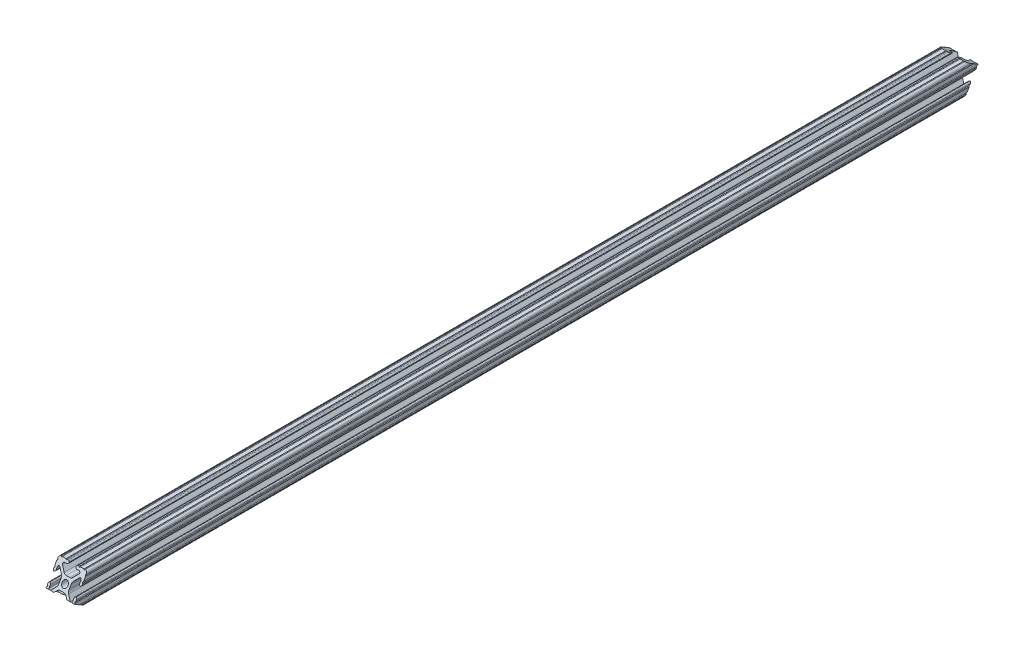
from build123d import *

# Parameters (mm, degrees)
SKETCH1_R                    = 2.6035
BOSS_EXTRUDE1_DEPTH          = 403.225
F_30_DEG_END_TRIM_DEPTH      = 13.7
F_30_DEG_END_TRIM_DEPTH_BACK = 13.7
TRIM_TO_FIT_DEPTH            = 13.7
TRIM_TO_FIT_DEPTH_BACK       = 13.7


with BuildPart() as part:
    # Sketch1 → Boss-Extrude1 (new body, symmetric)
    with BuildSketch(Plane.XY):
        with BuildLine():
            Line((-7.179650497, -8.645192506), (-3.952270251, -5.423690499))
            ThreePointArc((-3.952270251, -5.423690499), (-2.922936451, -4.736929036), (-1.709253557, -4.4958))
            Line((-1.709253557, -4.4958), (1.709253557, -4.4958))
            ThreePointArc((1.709253557, -4.4958), (2.922936451, -4.736929036), (3.952270251, -5.423690499))
            Line((3.952270251, -5.423690499), (7.179650497, -8.645192506))
            ThreePointArc((7.179650497, -8.645192506), (7.41473083, -9.822813117), (6.416408329, -10.4902))
            Line((6.416408329, -10.4902), (4.287512407, -10.4902))
            ThreePointArc((4.287512407, -10.4902), (3.54574862, -10.79744862), (3.2385, -11.539212407))
            Line((3.2385, -11.539212407), (3.2385, -11.650987593))
            ThreePointArc((3.2385, -11.650987593), (3.54574862, -12.39275138), (4.287512407, -12.7))
            Line((4.287512407, -12.7), (5.317126718, -12.7))
            ThreePointArc((5.317126718, -12.7), (5.825126718, -12.192), (6.333126718, -12.7))
            Line((6.333126718, -12.7), (9.550443118, -12.7))
            ThreePointArc((9.550443118, -12.7), (10.058366869, -12.192000006), (10.566443095, -12.699847501))
            ThreePointArc((10.566443095, -12.699847501), (12.082537762, -12.08250727), (12.699846982, -10.566399977))
            ThreePointArc((12.699846982, -10.566399977), (12.192000006, -10.058323491), (12.7, -9.5504))
            Line((12.7, -9.5504), (12.7, -6.3330836))
            ThreePointArc((12.7, -6.3330836), (12.192, -5.8250836), (12.7, -5.3170836))
            Line((12.7, -5.3170836), (12.7, -4.287469289))
            ThreePointArc((12.7, -4.287469289), (12.39275138, -3.545705502), (11.650987593, -3.238456882))
            Line((11.650987593, -3.238456882), (11.539212407, -3.238456882))
            ThreePointArc((11.539212407, -3.238456882), (10.79744862, -3.545705502), (10.4902, -4.287469289))
            Line((10.4902, -4.287469289), (10.4902, -6.402089023))
            ThreePointArc((10.4902, -6.402089023), (9.856505071, -7.351067942), (8.737131347, -7.129408934))
            Line((8.737131347, -7.129408934), (5.441005833, -3.840816462))
            ThreePointArc((5.441005833, -3.840816462), (4.750877967, -2.809883091), (4.5085, -1.593185507))
            Line((4.5085, -1.593185507), (4.5085, 1.593185507))
            ThreePointArc((4.5085, 1.593185507), (4.750877967, 2.809883091), (5.441005833, 3.840816462))
            Line((5.441005833, 3.840816462), (8.737131347, 7.129408934))
            ThreePointArc((8.737131347, 7.129408934), (9.856505071, 7.351067942), (10.4902, 6.402089023))
            Line((10.4902, 6.402089023), (10.4902, 4.287469289))
            ThreePointArc((10.4902, 4.287469289), (10.79744862, 3.545705502), (11.539212407, 3.238456882))
            Line((11.539212407, 3.238456882), (11.650987593, 3.238456882))
            ThreePointArc((11.650987593, 3.238456882), (12.39275138, 3.545705502), (12.7, 4.287469289))
            Line((12.7, 4.287469289), (12.7, 5.3170836))
            ThreePointArc((12.7, 5.3170836), (12.192, 5.8250836), (12.7, 6.3330836))
            Line((12.7, 6.3330836), (12.7, 9.5504))
            ThreePointArc((12.7, 9.5504), (12.192000006, 10.058323491), (12.699846982, 10.566399977))
            ThreePointArc((12.699846982, 10.566399977), (12.082537762, 12.08250727), (10.566443095, 12.699847501))
            ThreePointArc((10.566443095, 12.699847501), (10.058366869, 12.192000006), (9.550443118, 12.7))
            Line((9.550443118, 12.7), (6.333126718, 12.7))
            ThreePointArc((6.333126718, 12.7), (5.825126718, 12.192), (5.317126718, 12.7))
            Line((5.317126718, 12.7), (4.287512407, 12.7))
            ThreePointArc((4.287512407, 12.7), (3.54574862, 12.39275138), (3.2385, 11.650987593))
            Line((3.2385, 11.650987593), (3.2385, 11.539212407))
            ThreePointArc((3.2385, 11.539212407), (3.54574862, 10.79744862), (4.287512407, 10.4902))
            Line((4.287512407, 10.4902), (6.476788598, 10.4902))
            ThreePointArc((6.476788598, 10.4902), (7.432222385, 9.85140422), (7.207036008, 8.724370562))
            Line((7.207036008, 8.724370562), (3.898272566, 5.423169045))
            ThreePointArc((3.898272566, 5.423169045), (2.869120213, 4.736787962), (1.655778399, 4.4958))
            Line((1.655778399, 4.4958), (-1.655778399, 4.4958))
            ThreePointArc((-1.655778399, 4.4958), (-2.869120213, 4.736787962), (-3.898272566, 5.423169045))
            Line((-3.898272566, 5.423169045), (-7.207036008, 8.724370562))
            ThreePointArc((-7.207036008, 8.724370562), (-7.432222385, 9.85140422), (-6.476788598, 10.4902))
            Line((-6.476788598, 10.4902), (-4.287512407, 10.4902))
            ThreePointArc((-4.287512407, 10.4902), (-3.54574862, 10.79744862), (-3.2385, 11.539212407))
            Line((-3.2385, 11.539212407), (-3.2385, 11.650987593))
            ThreePointArc((-3.2385, 11.650987593), (-3.54574862, 12.39275138), (-4.287512407, 12.7))
            Line((-4.287512407, 12.7), (-5.317126718, 12.7))
            ThreePointArc((-5.317126718, 12.7), (-5.825126718, 12.192), (-6.333126718, 12.7))
            Line((-6.333126718, 12.7), (-9.550443118, 12.7))
            ThreePointArc((-9.550443118, 12.7), (-10.058366869, 12.192000006), (-10.566443095, 12.699847501))
            ThreePointArc((-10.566443095, 12.699847501), (-12.082537762, 12.08250727), (-12.699846982, 10.566399977))
            ThreePointArc((-12.699846982, 10.566399977), (-12.192000006, 10.058323491), (-12.7, 9.5504))
            Line((-12.7, 9.5504), (-12.7, 6.3330836))
            ThreePointArc((-12.7, 6.3330836), (-12.192, 5.8250836), (-12.7, 5.3170836))
            Line((-12.7, 5.3170836), (-12.7, 4.287469289))
            ThreePointArc((-12.7, 4.287469289), (-12.39275138, 3.545705502), (-11.650987593, 3.238456882))
            Line((-11.650987593, 3.238456882), (-11.539212407, 3.238456882))
            ThreePointArc((-11.539212407, 3.238456882), (-10.79744862, 3.545705502), (-10.4902, 4.287469289))
            Line((-10.4902, 4.287469289), (-10.4902, 6.402089023))
            ThreePointArc((-10.4902, 6.402089023), (-9.856505071, 7.351067942), (-8.737131347, 7.129408934))
            Line((-8.737131347, 7.129408934), (-5.441005833, 3.840816462))
            ThreePointArc((-5.441005833, 3.840816462), (-4.750877967, 2.809883091), (-4.5085, 1.593185507))
            Line((-4.5085, 1.593185507), (-4.5085, -1.593185507))
            ThreePointArc((-4.5085, -1.593185507), (-4.750877967, -2.809883091), (-5.441005833, -3.840816462))
            Line((-5.441005833, -3.840816462), (-8.737131347, -7.129408934))
            ThreePointArc((-8.737131347, -7.129408934), (-9.856505071, -7.351067942), (-10.4902, -6.402089023))
            Line((-10.4902, -6.402089023), (-10.4902, -4.287469289))
            ThreePointArc((-10.4902, -4.287469289), (-10.79744862, -3.545705502), (-11.539212407, -3.238456882))
            Line((-11.539212407, -3.238456882), (-11.650987593, -3.238456882))
            ThreePointArc((-11.650987593, -3.238456882), (-12.39275138, -3.545705502), (-12.7, -4.287469289))
            Line((-12.7, -4.287469289), (-12.7, -5.3170836))
            ThreePointArc((-12.7, -5.3170836), (-12.192, -5.8250836), (-12.7, -6.3330836))
            Line((-12.7, -6.3330836), (-12.7, -9.5504))
            ThreePointArc((-12.7, -9.5504), (-12.192000006, -10.058323491), (-12.699846982, -10.566399977))
            ThreePointArc((-12.699846982, -10.566399977), (-12.082537762, -12.08250727), (-10.566443095, -12.699847501))
            ThreePointArc((-10.566443095, -12.699847501), (-10.058366869, -12.192000006), (-9.550443118, -12.7))
            Line((-9.550443118, -12.7), (-6.333126718, -12.7))
            ThreePointArc((-6.333126718, -12.7), (-5.825126718, -12.192), (-5.317126718, -12.7))
            Line((-5.317126718, -12.7), (-4.287512407, -12.7))
            ThreePointArc((-4.287512407, -12.7), (-3.54574862, -12.39275138), (-3.2385, -11.650987593))
            Line((-3.2385, -11.650987593), (-3.2385, -11.539212407))
            ThreePointArc((-3.2385, -11.539212407), (-3.54574862, -10.79744862), (-4.287512407, -10.4902))
            Line((-4.287512407, -10.4902), (-6.416408329, -10.4902))
            ThreePointArc((-6.416408329, -10.4902), (-7.41473083, -9.822813117), (-7.179650497, -8.645192506))
        make_face()
        Circle(SKETCH1_R, mode=Mode.SUBTRACT)
    extrude(amount=BOSS_EXTRUDE1_DEPTH, both=True)

    # Sketch2 → 30 Deg End Trim (cut, two sides)
    with BuildSketch(Plane(origin=(0, 0, 0), x_dir=(0, 0, -1), z_dir=(1, 0, 0))) as f_30_deg_end_trim_sk:
        Polygon((-403.225, -12.699847501), (-388.560479253, 12.699847501), (-388.560479253, 30.675819206), (-403.225, 30.675819206), (-403.225, 12.699847501), align=None)
        Polygon((403.225, -12.699847501), (403.225, 12.699847501), (381.811418901, -24.389562935), (391.735479253, -24.391206459), (403.225, -24.391206459), align=None)
    extrude(amount=F_30_DEG_END_TRIM_DEPTH, mode=Mode.SUBTRACT)
    extrude(f_30_deg_end_trim_sk.sketch, amount=-F_30_DEG_END_TRIM_DEPTH_BACK, mode=Mode.SUBTRACT)

    # Sketch3 → Trim to Fit (cut, two sides)
    with BuildSketch(Plane(origin=(0, 0, 0), x_dir=(0, 0, -1), z_dir=(1, 0, 0))) as trim_to_fit_sk:
        Polygon((-402.43125, -5.825770859), (-423.077780638, -5.825770859), (-423.077780638, -25.399847501), (-384.402954744, -25.399847501), (-380.434204744, -18.525770859), align=None)
        Polygon((402.43125, 5.825770859), (411.263329156, 0.726567581), (422.901533851, 20.884529422), (384.402954744, 25.399847501), (380.434204744, 18.525770859), align=None)
    extrude(amount=TRIM_TO_FIT_DEPTH, mode=Mode.SUBTRACT)
    extrude(trim_to_fit_sk.sketch, amount=-TRIM_TO_FIT_DEPTH_BACK, mode=Mode.SUBTRACT)


solid = part.part
